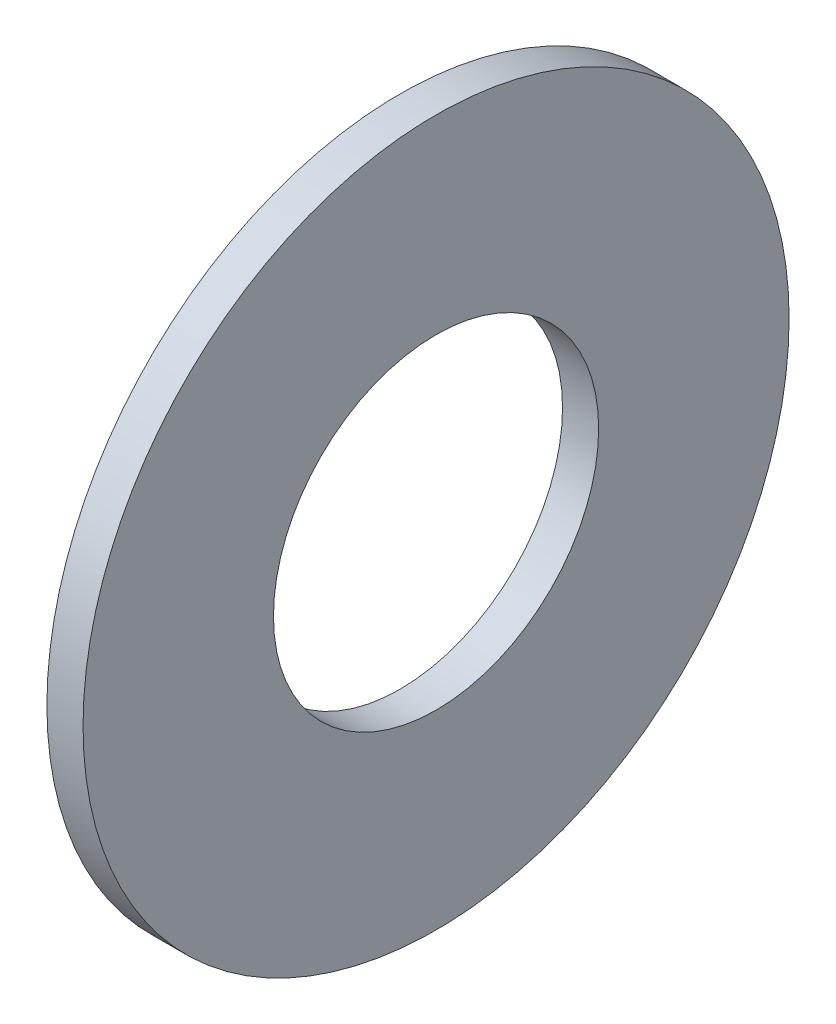
from build123d import *

# Parameters (mm, degrees)
SKETCH1_R           = 4.885
SKETCH1_R_2         = 2.25
BOSS_EXTRUDE1_DEPTH = 0.5


with BuildPart() as part:
    # Sketch1 → Boss-Extrude1 (new body)
    with BuildSketch(Plane(origin=(0, 0, 0), x_dir=(0, 0, -1), z_dir=(1, 0, 0))):
        Circle(SKETCH1_R)
        Circle(SKETCH1_R_2, mode=Mode.SUBTRACT)
    extrude(amount=BOSS_EXTRUDE1_DEPTH)


solid = part.part
